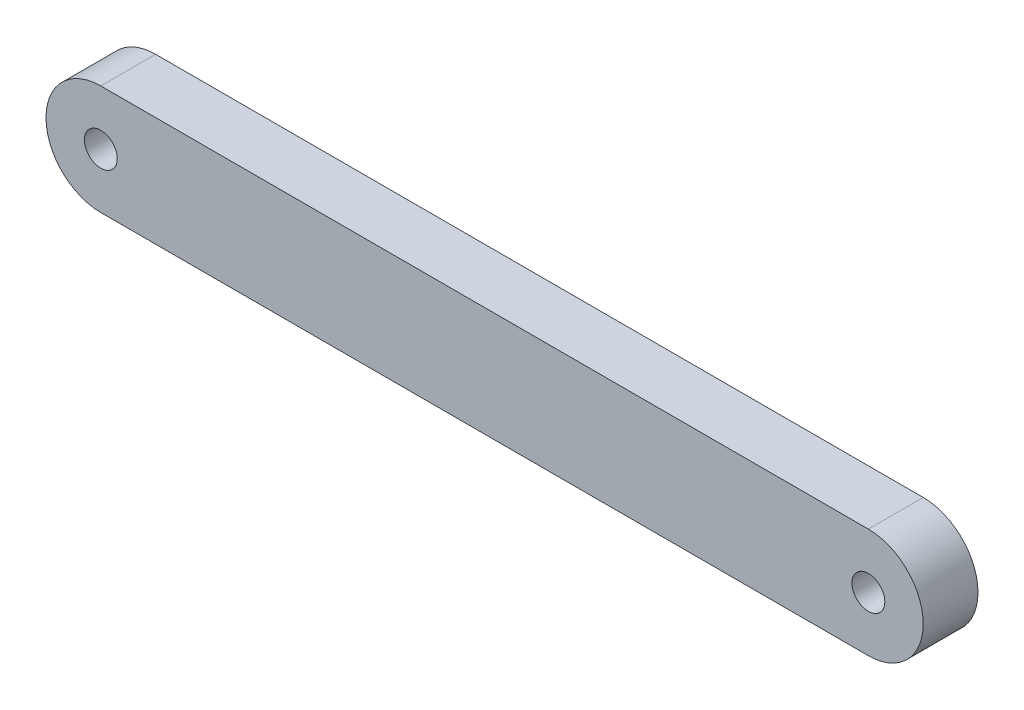
from build123d import *

# Parameters (mm, degrees)
BOSS_EXTRUDE1_DEPTH = 25
SKETCH2_R           = 15
CUT_EXTRUDE1_DEPTH  = 51


with BuildPart() as part:
    # Sketch1 → Boss-Extrude1 (new body, symmetric)
    with BuildSketch(Plane.XY):
        with BuildLine():
            Line((-350, 50), (350, 50))
            ThreePointArc((350, 50), (400, 0), (350, -50))
            Line((350, -50), (-350, -50))
            ThreePointArc((-350, -50), (-400, 0), (-350, 50))
        make_face()
    extrude(amount=BOSS_EXTRUDE1_DEPTH, both=True)

    # Sketch2 → Cut-Extrude1 (cut, through all)
    with BuildSketch(Plane.XY.offset(25)):
        with Locations((-350, 0)):
            Circle(SKETCH2_R)
        with Locations((350, 0)):
            Circle(SKETCH2_R)
    extrude(amount=-CUT_EXTRUDE1_DEPTH, mode=Mode.SUBTRACT)


solid = part.part
